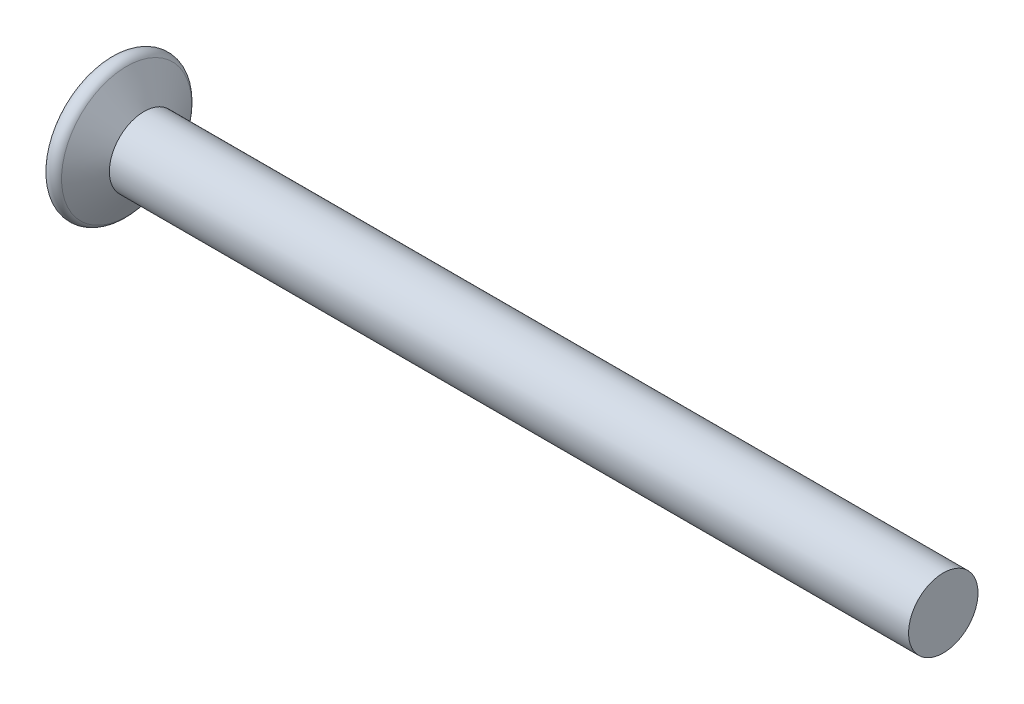
from build123d import *

# Parameters (mm, degrees)
RESSALTO_EXTRUS_O1_DEPTH = 1
PADR_OCIRCULAR1_COUNT    = 4


with BuildPart() as part:
    # Esboço1 → Revolução1 (revolve)
    with BuildSketch(Plane(origin=(0, 0, 0), x_dir=(1, 0, 0), z_dir=(0, 1, 0))):
        with BuildLine():
            Line((1.221687836, 1.25), (30, 1.25))
            Line((30, 1.25), (30, 0))
            Line((30, 0), (1.25, 0))
            Line((1.25, 0), (0, 1.25))
            Line((0, 1.25), (0, 2.183012702))
            ThreePointArc((0, 2.183012702), (0.234944948, 2.48919892), (0.591506351, 2.341506351))
            Line((0.591506351, 2.341506351), (1.221687836, 1.25))
        make_face()
    revolve(axis=Axis((0, 0, 0), (-1, 0, 0)))

    # Esboço2 → Ressalto-extrusão1 (add)
    with BuildSketch(Plane(origin=(0, 0, 0), x_dir=(0, 0, -1), z_dir=(1, 0, 0))):
        with BuildLine():
            Line((-0.3, 1.21346611), (-0.3, 0.6))
            ThreePointArc((-0.3, 0.6), (-0.387867966, 0.387867966), (-0.6, 0.3))
            Line((-0.6, 0.3), (-1.21346611, 0.3))
            ThreePointArc((-1.21346611, 0.3), (-0.924029762, 0.924029762), (-0.3, 1.21346611))
        make_face()
    ressalto_extrus_o1 = extrude(amount=RESSALTO_EXTRUS_O1_DEPTH)

    # PadrãoCircular1: Ressalto-extrusão1 ×4 about axis
    padr_ocircular1_axis = Axis((0, 0, 0), (1, 0, 0))
    for i in range(1, PADR_OCIRCULAR1_COUNT):
        add(ressalto_extrus_o1.rotate(padr_ocircular1_axis, i * 360 / PADR_OCIRCULAR1_COUNT))


solid = part.part
